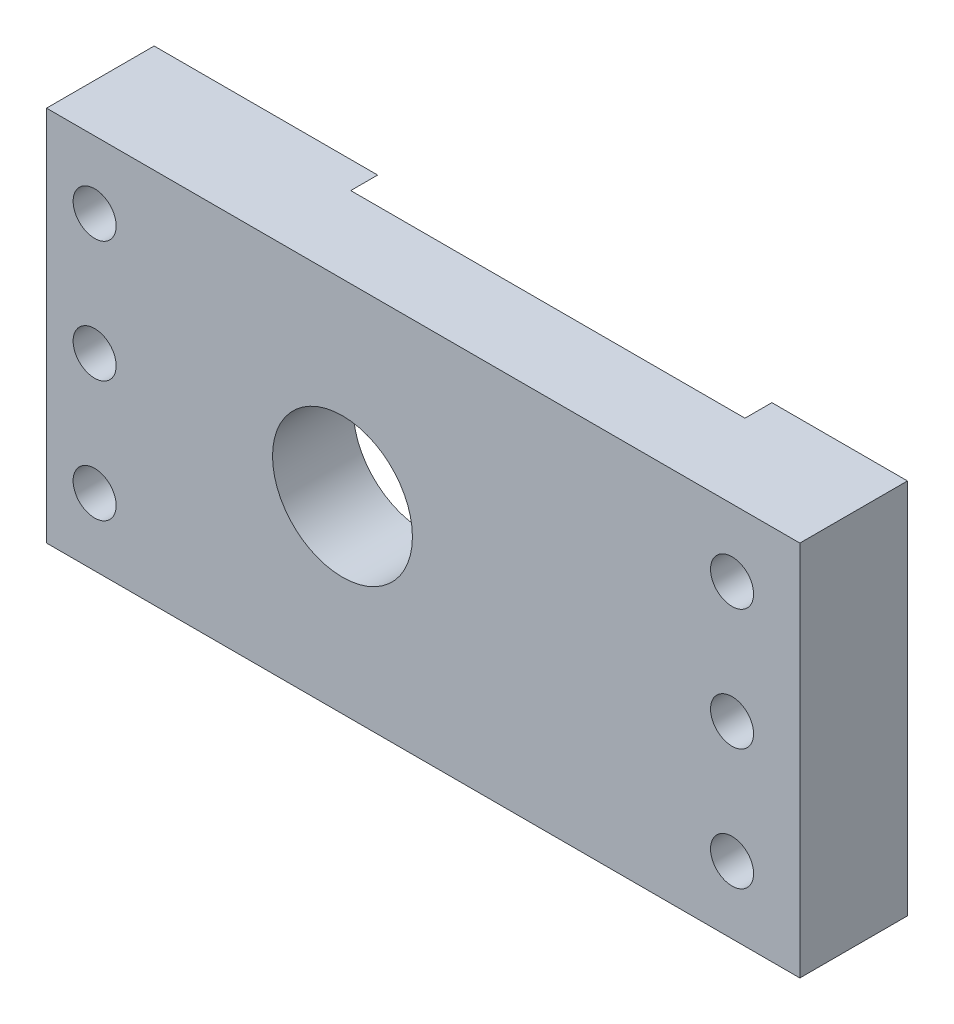
from build123d import *

# Parameters (mm, degrees)
SKETCH1_W           = 140
SKETCH1_H           = 70
SKETCH1_R           = 13
SKETCH1_R_2         = 4
BOSS_EXTRUDE1_DEPTH = 10
CUT_EXTRUDE1_DEPTH  = 5


with BuildPart() as part:
    # Sketch1 → Boss-Extrude1 (new body, symmetric)
    with BuildSketch(Plane.XY):
        Rectangle(SKETCH1_W, SKETCH1_H)
        with Locations((-15, 0)):
            Circle(SKETCH1_R, mode=Mode.SUBTRACT)
        with Locations((57.4, 0)):
            Circle(SKETCH1_R_2, mode=Mode.SUBTRACT)
        with Locations((57.4, 22.5)):
            Circle(SKETCH1_R_2, mode=Mode.SUBTRACT)
        with Locations((-61.06, 0)):
            Circle(SKETCH1_R_2, mode=Mode.SUBTRACT)
        with Locations((-61.06, 22.5)):
            Circle(SKETCH1_R_2, mode=Mode.SUBTRACT)
        with Locations((-61.06, -22.5)):
            Circle(SKETCH1_R_2, mode=Mode.SUBTRACT)
        with Locations((57.4, -22.5)):
            Circle(SKETCH1_R_2, mode=Mode.SUBTRACT)
    extrude(amount=BOSS_EXTRUDE1_DEPTH, both=True)

    # Sketch2 → Cut-Extrude1 (cut)
    with BuildSketch(Plane(origin=(0, 0, -10), x_dir=(-1, 0, 0), z_dir=(0, 0, -1))):
        with BuildLine():
            Line((15, -37.5), (-44.8, -37.5))
            Line((-44.8, -37.5), (-44.8, 37.5))
            Line((-44.8, 37.5), (15, 37.5))
            ThreePointArc((15, 37.5), (52.5, 0), (15, -37.5))
        make_face()
    extrude(amount=-CUT_EXTRUDE1_DEPTH, mode=Mode.SUBTRACT)


solid = part.part
